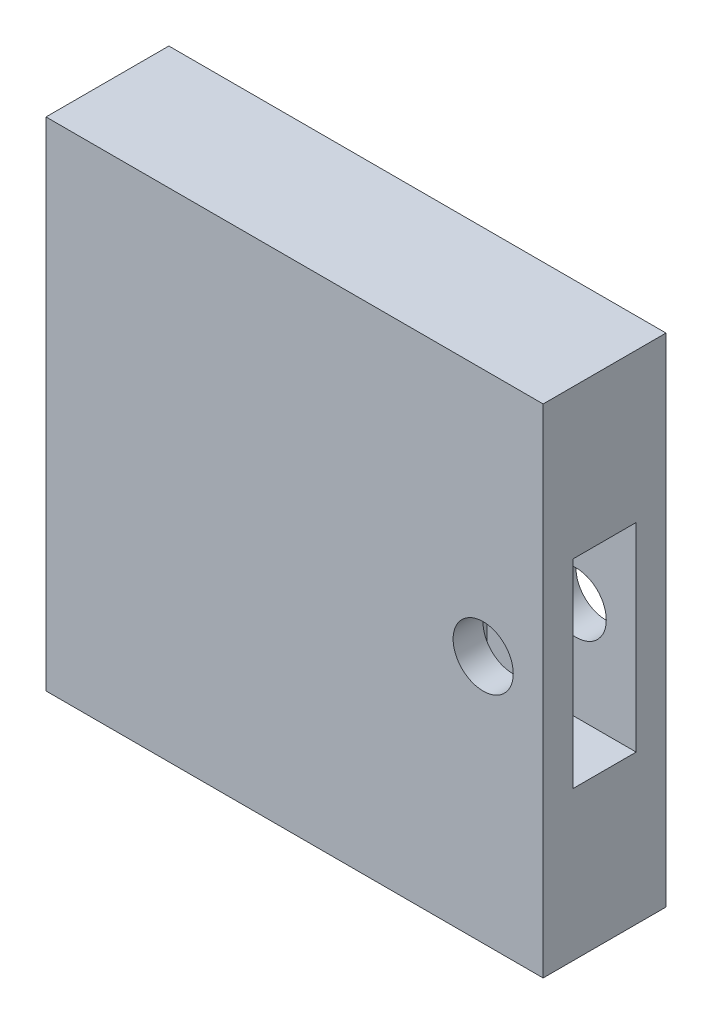
from build123d import *

# Parameters (mm, degrees)
SKETCH_1_W          = 50
SKETCH_1_H          = 50
EXTRUDE_1_DEPTH     = 12.355487047
SKETCH_2_R          = 3.024908428
CUT_EXTRUDE_1_DEPTH = 15
SKETCH_3_W          = 6.355487047
SKETCH_3_H          = 20
CUT_EXTRUDE_2_DEPTH = 15


with BuildPart() as part:
    # 草图1 → 凸台-拉伸1 (new body)
    with BuildSketch(Plane.XY):
        Rectangle(SKETCH_1_W, SKETCH_1_H)
    extrude(amount=EXTRUDE_1_DEPTH)

    # 草图2 → 切除-拉伸1 (cut)
    with BuildSketch(Plane.XY.offset(12.355487047)):
        with Locations((18.969094387, 0)):
            Circle(SKETCH_2_R)
    extrude(amount=-CUT_EXTRUDE_1_DEPTH, mode=Mode.SUBTRACT)

    # 草图3 → 切除-拉伸2 (cut)
    with BuildSketch(Plane(origin=(25, 0, 0), x_dir=(0, 0, -1), z_dir=(1, 0, 0))):
        with Locations((-6.177743524, 0)):
            Rectangle(SKETCH_3_W, SKETCH_3_H)
    extrude(amount=-CUT_EXTRUDE_2_DEPTH, mode=Mode.SUBTRACT)


solid = part.part
